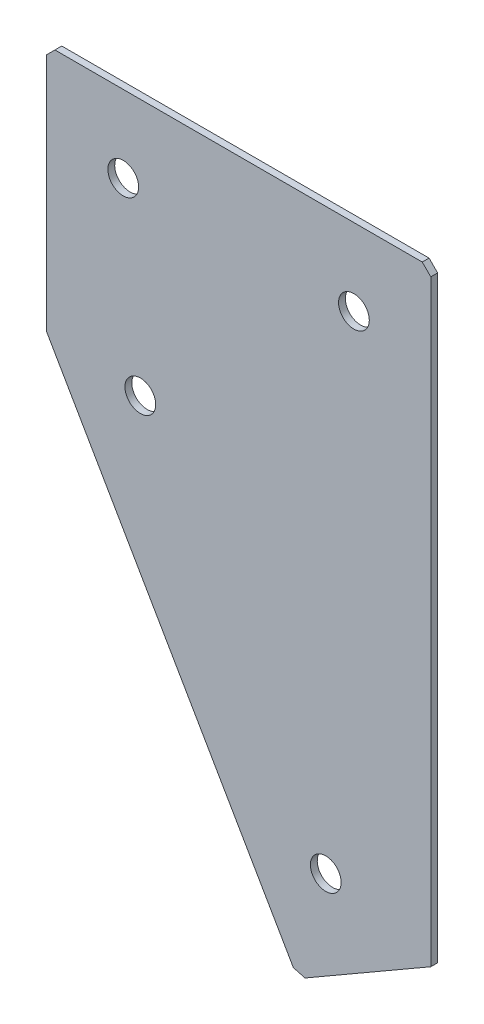
from build123d import *

# Parameters (mm, degrees)
EXTRUDE_1_DEPTH   = 2
HOLE_WIZARD_M81_D = 9
CHAMFER_1_SIZE    = 2.5


with BuildPart() as part:
    # Эскиз3 → Бобышка-Вытянуть1 (new body)
    with BuildSketch(Plane(origin=(0, 0, 0), x_dir=(1, 0, 0), z_dir=(0, 0, -1))):
        Polygon((0, 0), (112.5, 0), (112.5, 177.355715852), (73.52885683, 199.855715851), (0, 72.5), align=None)
    extrude(amount=EXTRUDE_1_DEPTH)

    # Отверстие с зазором M81 (through all)
    with Locations(Plane(origin=(0, 0, -2), x_dir=(1, 0, 0), z_dir=(0, 0, -1))):
        with Locations((22.5, 22.5), (90, 22.5), (27.5, 75.131397208), (81.764428415, 169.120144266)):
            Hole(HOLE_WIZARD_M81_D / 2)

    # Фаска1
    chamfer_1_edges = [part.edges().sort_by_distance(p)[0] for p in [
        (73.52885683, -199.855715851, -1),
        (112.5, 0, -1),
        (0, 0, -1),
    ]]
    chamfer(chamfer_1_edges, length=CHAMFER_1_SIZE)


solid = part.part
